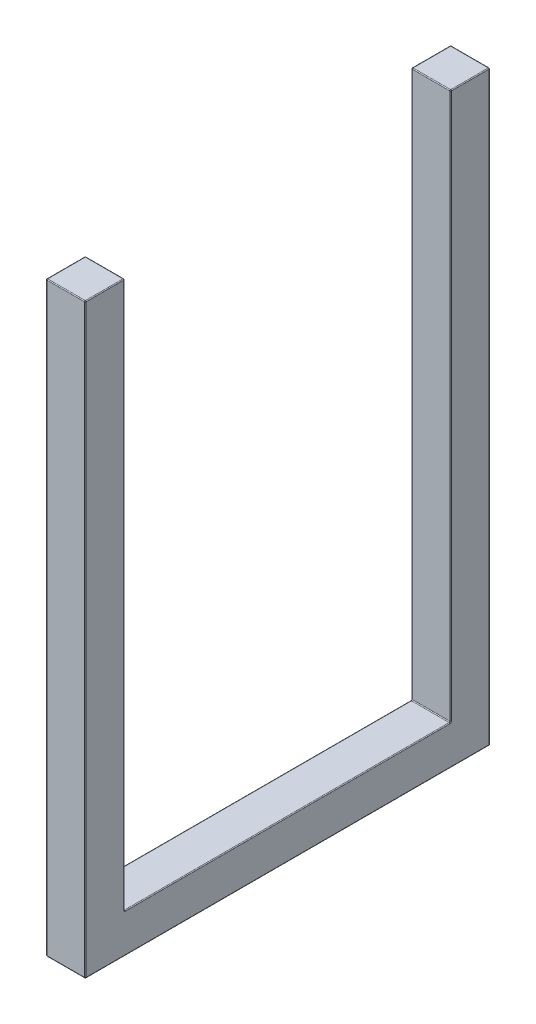
from build123d import *

# Parameters (mm, degrees)
SKETCH1_W             = 49.2125
SKETCH1_H             = 49.2125
BOSS_EXTRUDE1_DEPTH   = 736.6
BOSS_EXTRUDE1_2_DEPTH = 736.6
SKETCH2_W             = 49.2125
SKETCH2_H             = 49.2125
BOSS_EXTRUDE2_DEPTH   = 458.7875
FILLET1_R             = 1.016


with BuildPart() as part:
    # Sketch1 → Boss-Extrude1 (new body)
    with BuildSketch(Plane(origin=(0, 0, 0), x_dir=(1, 0, 0), z_dir=(0, 1, 0))):
        with Locations((-432.59375, 229.39375)):
            Rectangle(SKETCH1_W, SKETCH1_H)
    extrude(amount=BOSS_EXTRUDE1_DEPTH)



with BuildPart() as body_2:
    # Sketch1 → Boss-Extrude1 2 (new body)
    with BuildSketch(Plane(origin=(0, 0, 0), x_dir=(1, 0, 0), z_dir=(0, 1, 0))):
        with Locations((-432.59375, -229.39375)):
            Rectangle(SKETCH1_W, SKETCH1_H)
    extrude(amount=BOSS_EXTRUDE1_2_DEPTH)


with BuildPart() as part_1:
    add(part.part)

    add(body_2.part)  # Boss-Extrude2 merges body 2
    # Sketch2 → Boss-Extrude2 (add)
    with BuildSketch(Plane.XY.offset(-204.7875)):
        with Locations((-432.59375, 24.60625)):
            Rectangle(SKETCH2_W, SKETCH2_H)
    extrude(amount=BOSS_EXTRUDE2_DEPTH)

    # Fillet1
    fillet1_edges = [part_1.edges().sort_by_distance(p)[0] for p in [
        (-407.9875, 736.6, -229.39375),
        (-432.59375, 49.2125, 204.7875),
        (-407.9875, 49.2125, 0),
        (-432.59375, 49.2125, -204.7875),
        (-457.2, 49.2125, 0),
        (-432.59375, 736.6, -254),
        (-407.9875, 392.90625, 204.7875),
        (-432.59375, 0, 254),
        (-457.2, 368.3, 254),
        (-407.9875, 368.3, 254),
        (-457.2, 392.90625, 204.7875),
        (-432.59375, 736.6, 254),
        (-407.9875, 736.6, 229.39375),
        (-432.59375, 736.6, 204.7875),
        (-457.2, 736.6, 229.39375),
        (-457.2, 736.6, -229.39375),
        (-432.59375, 0, -254),
        (-407.9875, 0, 0),
        (-457.2, 0, 0),
        (-457.2, 368.3, -254),
        (-407.9875, 368.3, -254),
        (-407.9875, 392.90625, -204.7875),
        (-457.2, 392.90625, -204.7875),
        (-432.59375, 736.6, -204.7875),
    ]]
    fillet(fillet1_edges, radius=FILLET1_R)


solid = part_1.part
